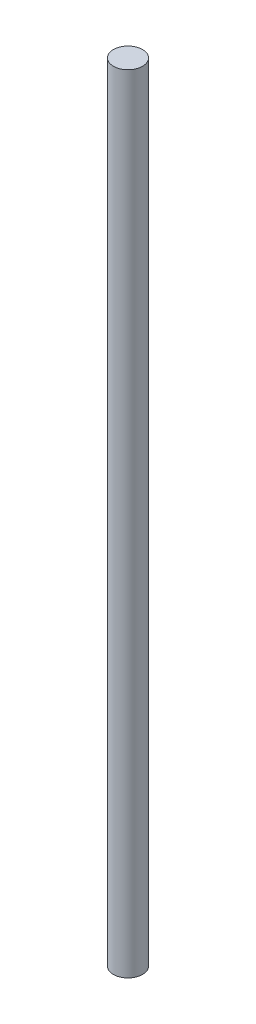
from build123d import *

# Parameters (mm, degrees)
SKETCH1_R           = 4.9
BOSS_EXTRUDE1_DEPTH = 265


with BuildPart() as part:
    # Sketch1 → Boss-Extrude1 (new body)
    with BuildSketch(Plane(origin=(0, 0, 0), x_dir=(1, 0, 0), z_dir=(0, 1, 0))):
        Circle(SKETCH1_R)
    extrude(amount=BOSS_EXTRUDE1_DEPTH)


solid = part.part
